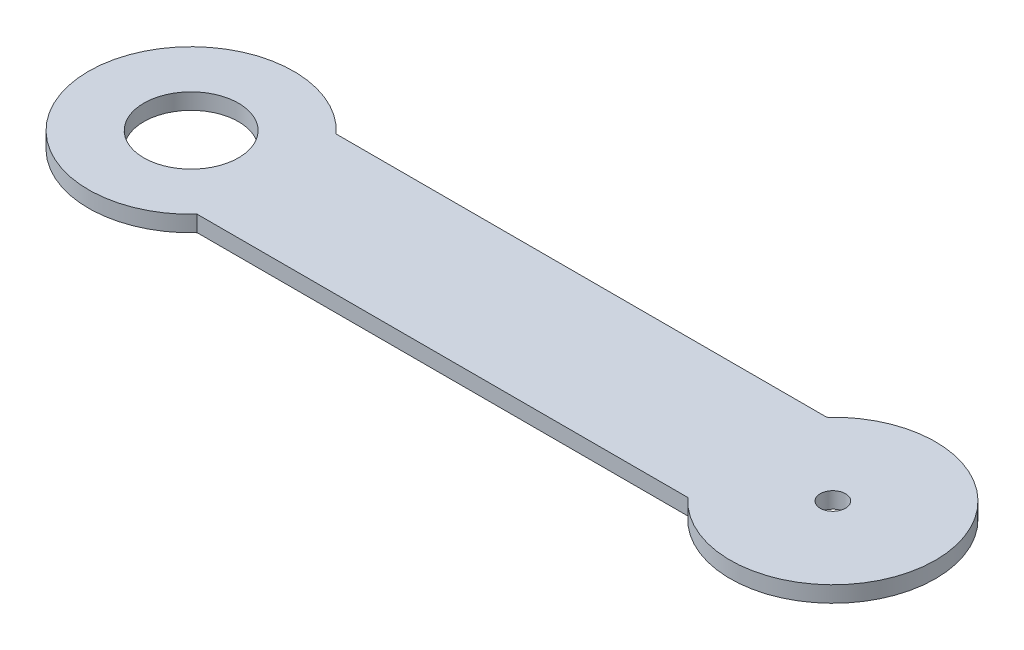
from build123d import *

# Parameters (mm, degrees)
BOSS_EXTRUDE1_DEPTH = 2.54
SKETCH2_R           = 7.5
SKETCH2_R_2         = 2
CUT_EXTRUDE1_DEPTH  = 2.54


with BuildPart() as part:
    # Sketch1 → Boss-Extrude1 (new body)
    with BuildSketch(Plane(origin=(0, 0, 0), x_dir=(1, 0, 0), z_dir=(0, 1, 0))):
        with BuildLine():
            Line((-38.836017598, 11), (38.836017598, 11))
            ThreePointArc((38.836017598, 11), (67.052288298, 0), (38.836017598, -11))
            Line((38.836017598, -11), (-38.836017598, -11))
            ThreePointArc((-38.836017598, -11), (-67.052288298, 0), (-38.836017598, 11))
        make_face()
    extrude(amount=BOSS_EXTRUDE1_DEPTH)

    # Sketch2 → Cut-Extrude1 (cut)
    with BuildSketch(Plane(origin=(0, 2.54, 0), x_dir=(1, 0, 0), z_dir=(0, 1, 0))):
        with Locations((-50.8, 0)):
            Circle(SKETCH2_R)
        with Locations((50.8, 0)):
            Circle(SKETCH2_R_2)
    extrude(amount=-CUT_EXTRUDE1_DEPTH, mode=Mode.SUBTRACT)


solid = part.part
